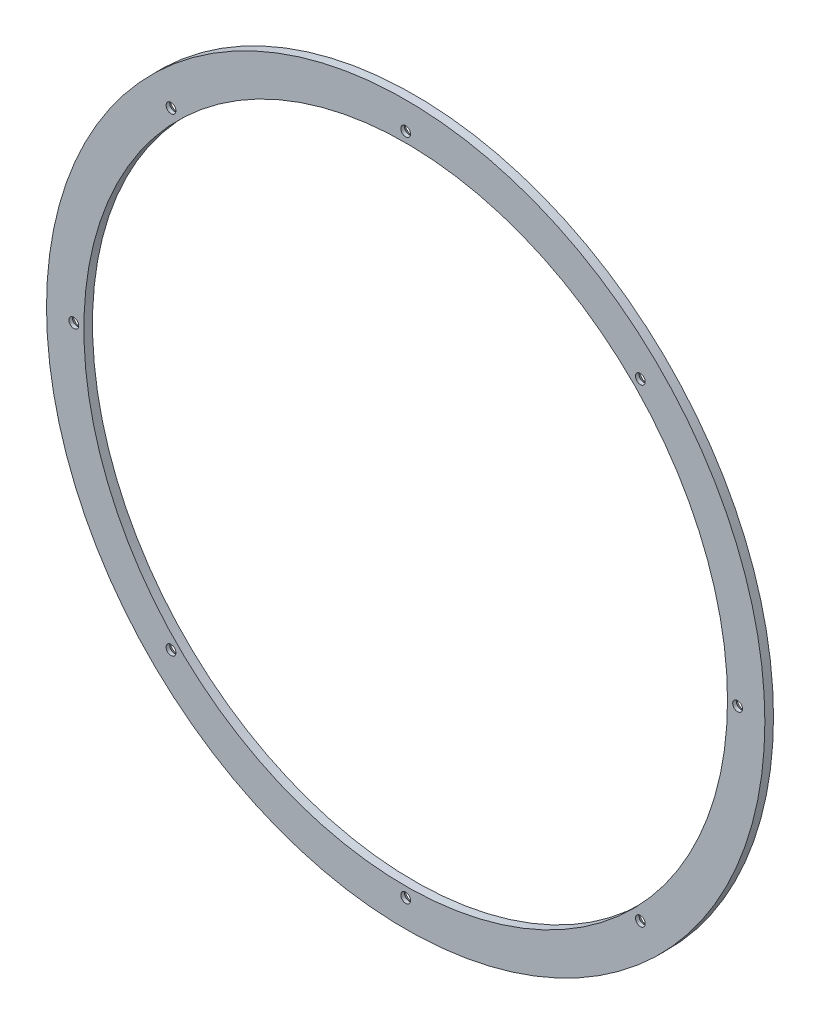
from build123d import *

# Parameters (mm, degrees)
SKETCH1_R           = 125
SKETCH1_R_2         = 112
BOSS_EXTRUDE1_DEPTH = 3
CIRPATTERN1_COUNT   = 8


with BuildPart() as part:
    # Sketch1 → Boss-Extrude1 (new body)
    with BuildSketch(Plane.XY):
        Circle(SKETCH1_R)
        Circle(SKETCH1_R_2, mode=Mode.SUBTRACT)
    extrude(amount=BOSS_EXTRUDE1_DEPTH)

    # Sketch3 → CSK for M3 Countersunk Flat Head Screw1 (revolve, cut)
    with BuildSketch(Plane.YZ.offset(-115.5)):
        Polygon((0, 0), (0, 3), (1.7, 3), (1.7, 1.75), (3.45, 0), align=None)
    csk_for_m3_countersunk_flat_head_screw1 = revolve(axis=Axis((-115.5, 0, -6.35), (0, 0, 1)), mode=Mode.SUBTRACT)

    # CirPattern1: CSK for M3 Countersunk Flat Head Screw1 ×8 about axis
    cirpattern1_axis = Axis((0, 0, 0), (0, 0, 1))
    for i in range(1, CIRPATTERN1_COUNT):
        add(csk_for_m3_countersunk_flat_head_screw1.rotate(cirpattern1_axis, i * 360 / CIRPATTERN1_COUNT), mode=Mode.SUBTRACT)


solid = part.part
